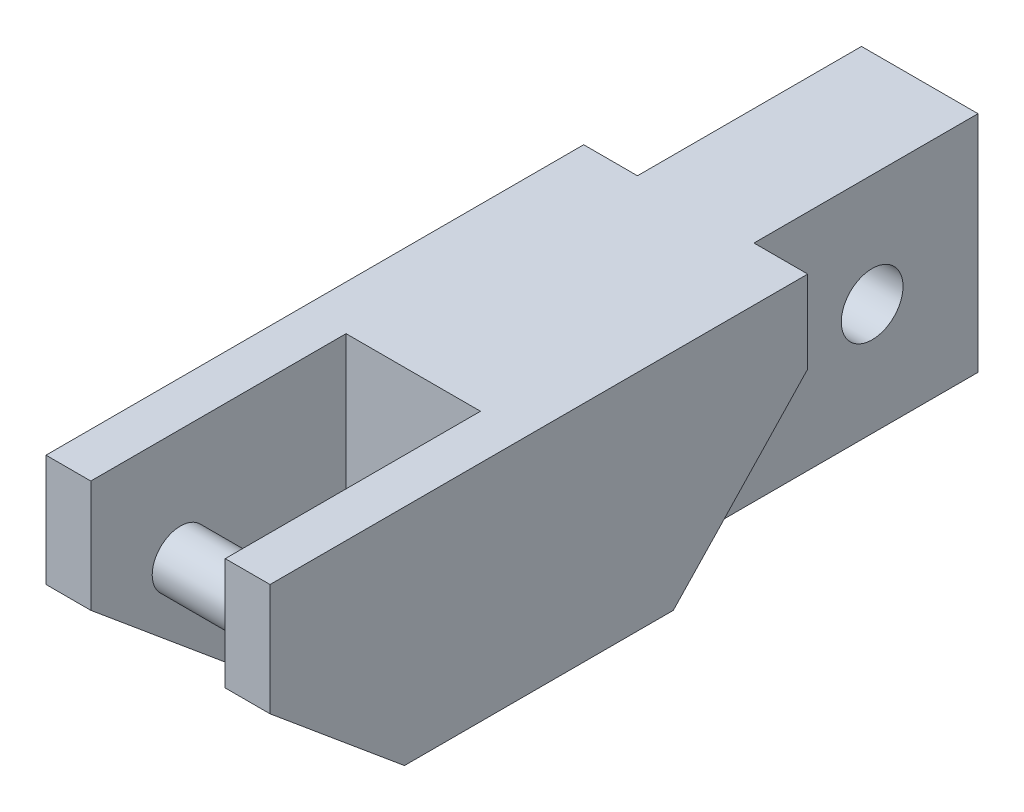
from build123d import *

# Parameters (mm, degrees)
SKETCH2_W           = 6.604
SKETCH2_H           = 12.7
SKETCH2_W_2         = 2.54
SKETCH2_H_2         = 14.47
BOSS_EXTRUDE1_DEPTH = 12.7
SKETCH3_R           = 1.75
CUT_EXTRUDE1_DEPTH  = 32.27817965
BOSS_EXTRUDE4_START = -18.57818
SKETCH3_3_R         = 1.6
BOSS_EXTRUDE4_DEPTH = 12.7
CUT_EXTRUDE12_DEPTH = 13.70000035
CUT_EXTRUDE14_DEPTH = 3.048
SKETCH37_W          = 1.6
SKETCH37_H          = 28.71
CUT_EXTRUDE17_DEPTH = 3.175
SKETCH38_W          = 1.677757264
SKETCH38_H          = 8.39
BOSS_EXTRUDE7_DEPTH = 1.5875


with BuildPart() as part:
    # Sketch2 → Boss-Extrude1 (new body)
    with BuildSketch(Plane(origin=(0, 0, 0), x_dir=(1, 0, 0), z_dir=(0, 1, 0))):
        Polygon((-28.23017965, 12.02419618), (-31.27817965, 12.02419618), (-31.27817965, -3.98580382), (-28.73817965, -3.98580382), (-21.11817965, -3.98580382), (-18.57817965, -3.98580382), (-18.57817965, 12.02419618), (-21.62617965, 12.02419618), align=None)
        with Locations((-24.92817965, 18.37419618)):
            Rectangle(SKETCH2_W, SKETCH2_H)
        with Locations((-19.84817965, -11.22080382)):
            Rectangle(SKETCH2_W_2, SKETCH2_H_2)
        with Locations((-30.00817965, -11.22080382)):
            Rectangle(SKETCH2_W_2, SKETCH2_H_2)
    extrude(amount=BOSS_EXTRUDE1_DEPTH)

    # Sketch3 → Cut-Extrude1 (cut, through all)
    with BuildSketch(Plane(origin=(0, 0, 0), x_dir=(0, 0, -1), z_dir=(1, 0, 0))):
        with Locations((18.72419618, 6.35)):
            Circle(SKETCH3_R)
    extrude(amount=-CUT_EXTRUDE1_DEPTH, mode=Mode.SUBTRACT)

    # Sketch3_3 → Boss-Extrude4 (add, through all)
    with BuildSketch(Plane(origin=(0, 0, 0), x_dir=(0, 0, -1), z_dir=(1, 0, 0)).offset(BOSS_EXTRUDE4_START)):
        with Locations((-13.37580382, 6.35)):
            Circle(SKETCH3_3_R)
    extrude(amount=-BOSS_EXTRUDE4_DEPTH)

    # Sketch29 → Cut-Extrude12 (cut, through all)
    with BuildSketch(Plane(origin=(-18.57817965, 0, 0), x_dir=(0, 0, -1), z_dir=(1, 0, 0))):
        Polygon((-18.45580382, 6.35), (-10.83580382, 0), (-18.45580382, 0), align=None)
    extrude(amount=-CUT_EXTRUDE12_DEPTH, mode=Mode.SUBTRACT)

    # Sketch31 → Cut-Extrude14 (cut)
    with BuildSketch(Plane(origin=(-18.57817965, 0, 0), x_dir=(0, 0, -1), z_dir=(1, 0, 0))):
        Polygon((12.02419618, 8.039800124), (4.40419618, 0), (12.02419618, 0), align=None)
    extrude(amount=-CUT_EXTRUDE14_DEPTH, mode=Mode.SUBTRACT)

    # Sketch37 → Cut-Extrude17 (cut)
    with BuildSketch(Plane.XZ):
        with Locations((-24.92817965, -10.36919618)):
            Rectangle(SKETCH37_W, SKETCH37_H)
    extrude(amount=-CUT_EXTRUDE17_DEPTH, mode=Mode.SUBTRACT)

    # Sketch38 → Boss-Extrude7 (add)
    with BuildSketch(Plane.XZ):
        with Locations((-24.889301018, -0.20919618)):
            Rectangle(SKETCH38_W, SKETCH38_H)
    extrude(amount=-BOSS_EXTRUDE7_DEPTH)


solid = part.part
